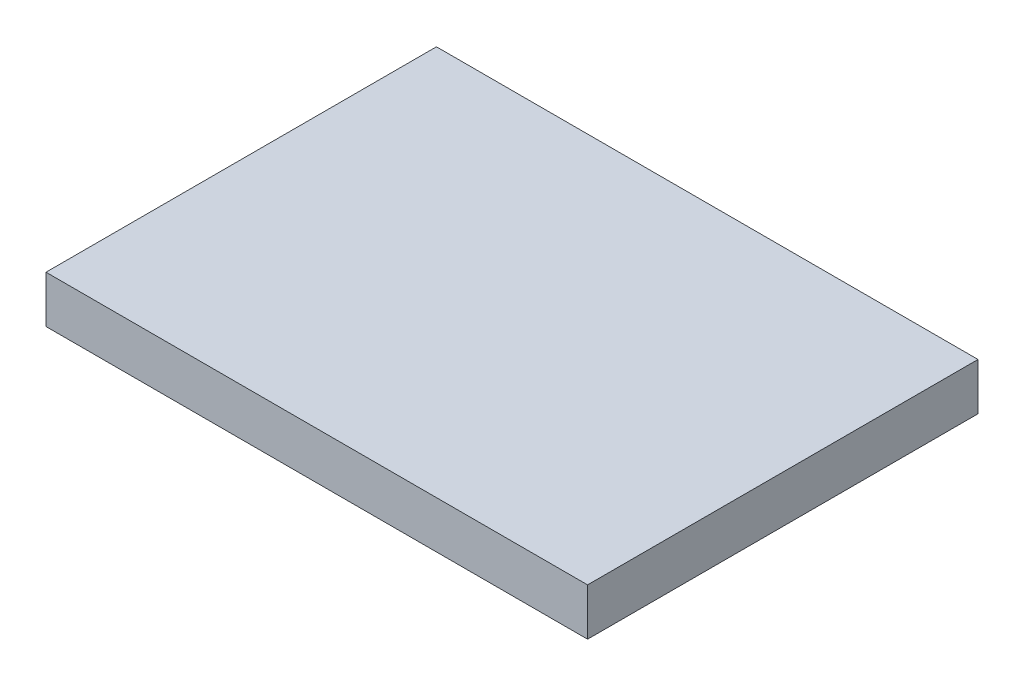
from build123d import *

# Parameters (mm, degrees)
SKETCH1_W           = 54.801555654
SKETCH1_H           = 39.508098262
BOSS_EXTRUDE1_DEPTH = 4.7625


with BuildPart() as part:
    # Sketch1 → Boss-Extrude1 (new body)
    with BuildSketch(Plane(origin=(0, 0, 0), x_dir=(1, 0, 0), z_dir=(0, 1, 0))):
        with Locations((27.400777827, 19.754049131)):
            Rectangle(SKETCH1_W, SKETCH1_H)
    extrude(amount=BOSS_EXTRUDE1_DEPTH)


solid = part.part
